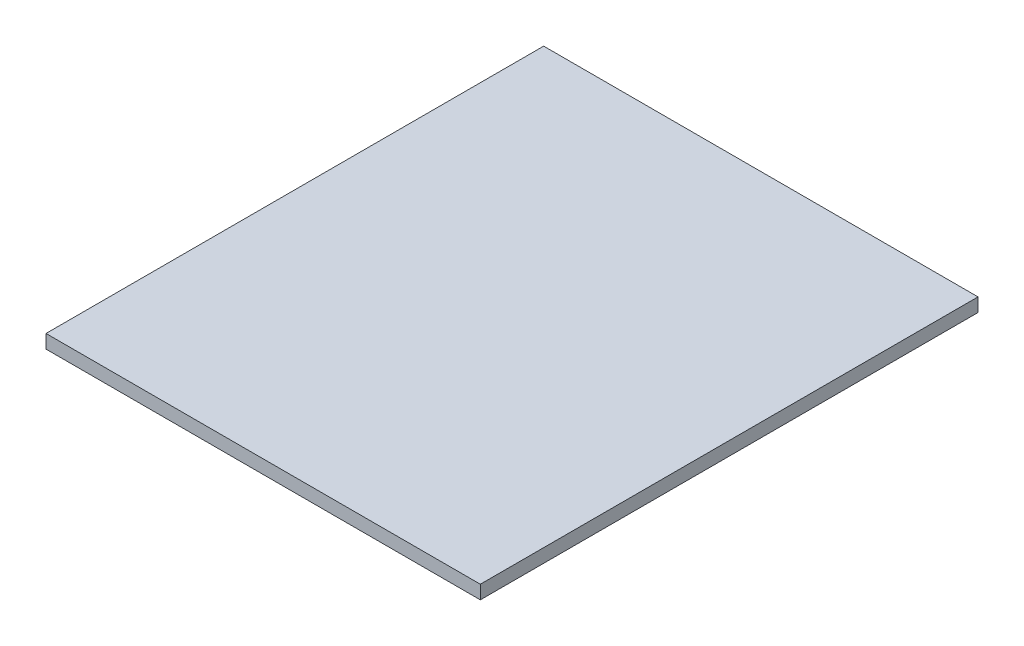
from build123d import *

# Parameters (mm, degrees)
SKIZZE1_W                       = 192
SKIZZE1_H                       = 220
AUFSATZ_LINEAR_AUSTRAGEN1_DEPTH = 6


with BuildPart() as part:
    # Skizze1 → Aufsatz-Linear austragen1 (new body)
    with BuildSketch(Plane(origin=(0, 0, 0), x_dir=(1, 0, 0), z_dir=(0, 1, 0))):
        with Locations((96, 110)):
            Rectangle(SKIZZE1_W, SKIZZE1_H)
    extrude(amount=AUFSATZ_LINEAR_AUSTRAGEN1_DEPTH)


solid = part.part
